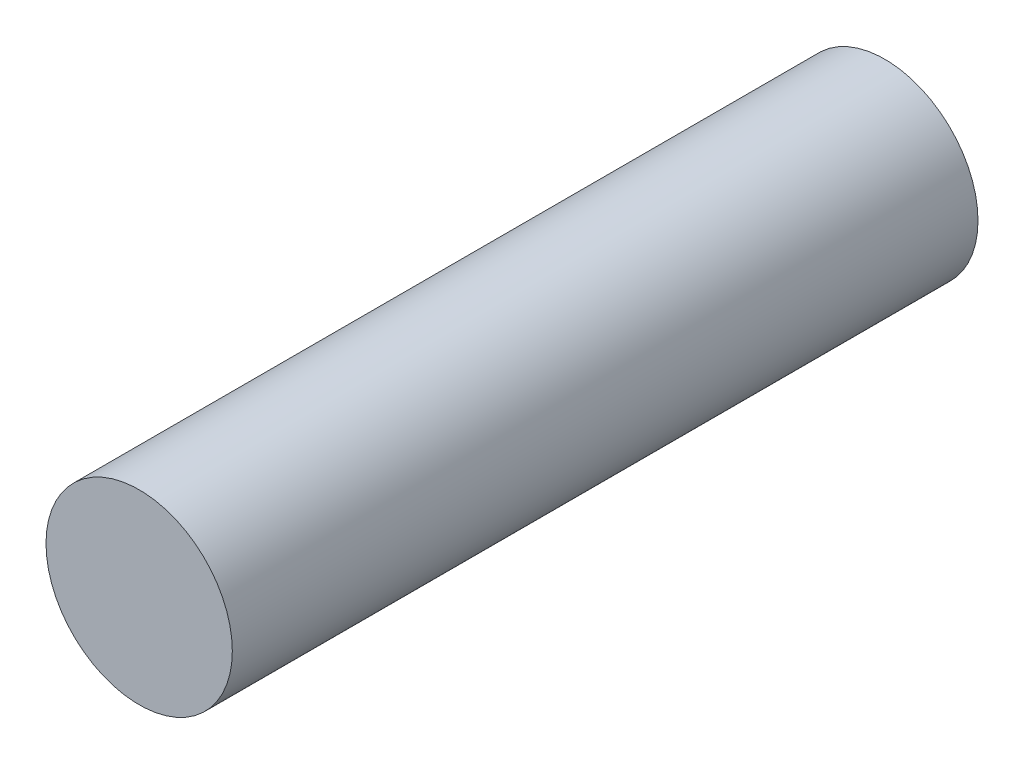
from build123d import *

# Parameters (mm, degrees)
SKETCH1_R           = 4.76
BOSS_EXTRUDE1_DEPTH = 38.1


with BuildPart() as part:
    # Sketch1 → Boss-Extrude1 (new body)
    with BuildSketch(Plane.XY):
        Circle(SKETCH1_R)
    extrude(amount=BOSS_EXTRUDE1_DEPTH)


solid = part.part
